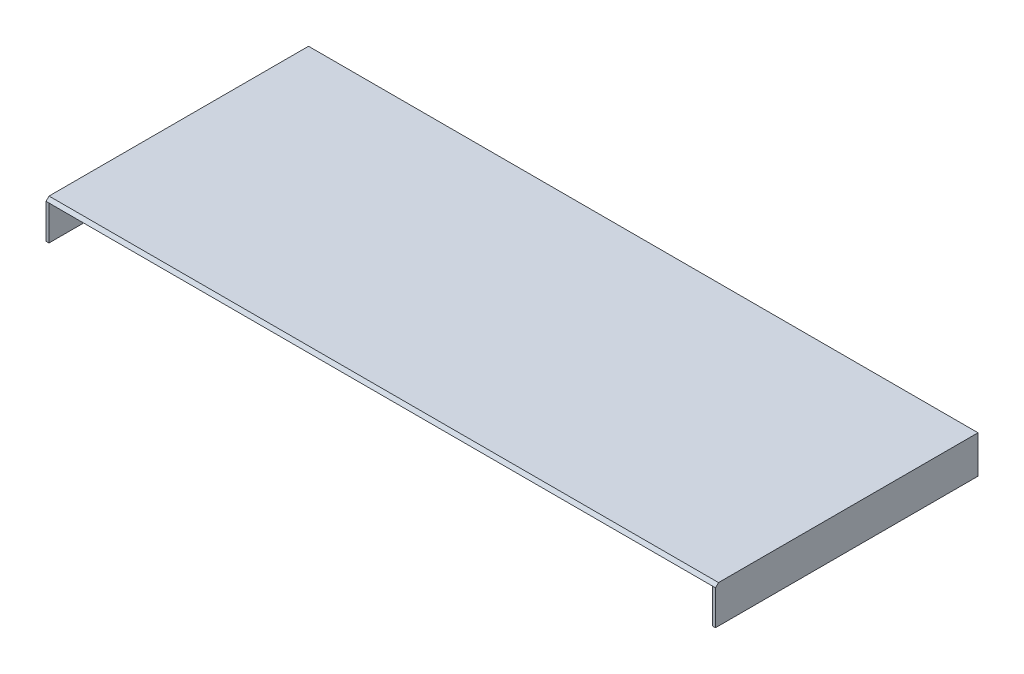
from build123d import *

# Parameters (mm, degrees)
DODANIE_WYCI_GNI_CIE3_DEPTH = 193.5
DODANIE_WYCI_GNI_CIE4_DEPTH = 20


with BuildPart() as part:
    # Szkic3 → Dodanie-wyciągnięcie3 (new body, symmetric)
    with BuildSketch(Plane(origin=(0, 0, 0), x_dir=(0, 0, -1), z_dir=(1, 0, 0))):
        Polygon((0, 0), (-150, 0), (-151.75, -1.75), (0, -1.75), align=None)
    extrude(amount=DODANIE_WYCI_GNI_CIE3_DEPTH, both=True)

    # Szkic4 → Dodanie-wyciągnięcie4 (add)
    with BuildSketch(Plane.XZ.offset(1.75)):
        Polygon((-193.5, 151.75), (-193.5, 0), (193.5, 0), (193.5, 151.75), (191.75, 151.75), (191.75, 1.75), (-191.75, 1.75), (-191.75, 151.75), align=None)
    extrude(amount=DODANIE_WYCI_GNI_CIE4_DEPTH)


solid = part.part
